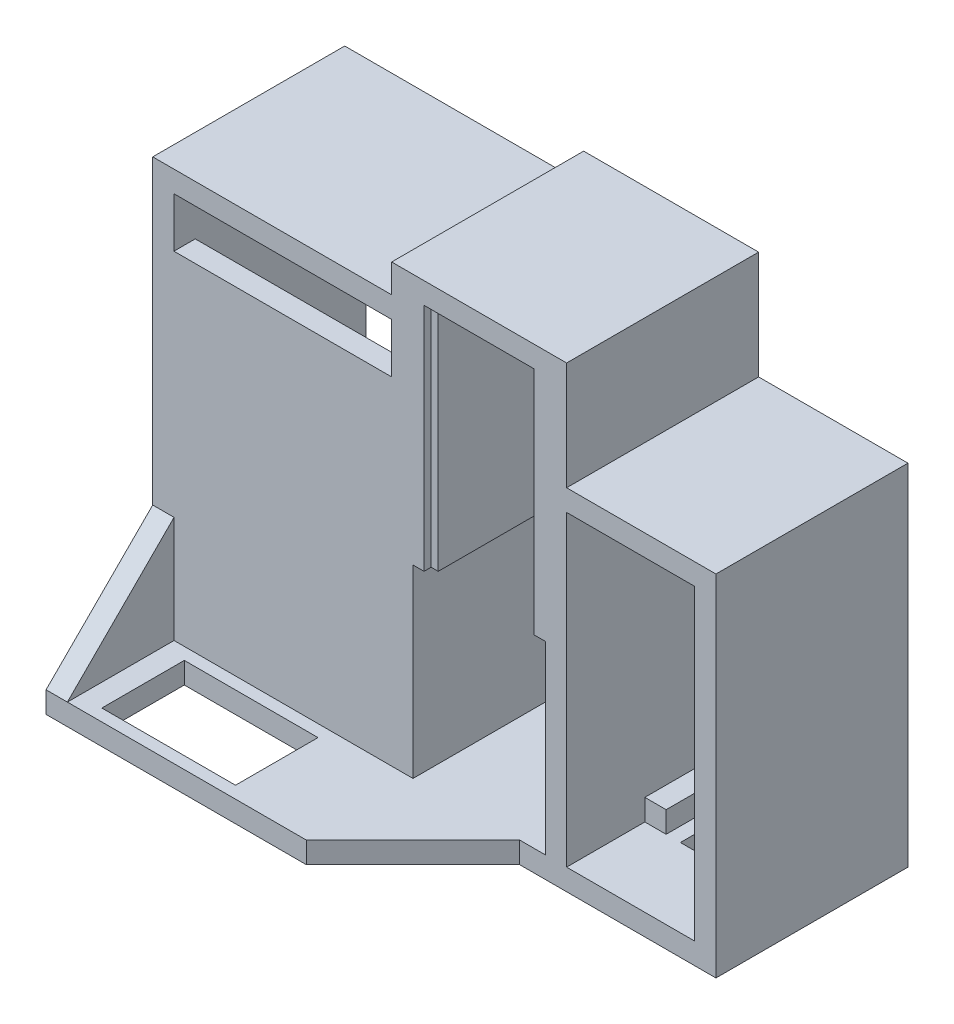
from build123d import *

# Parameters (mm, degrees)
SKETCH1_W            = 24.6
SKETCH1_H            = 64.4
BOSS_EXTRUDE1_DEPTH  = 3
SKETCH1_5_W          = 24.6
SKETCH1_5_H          = 64.4
BOSS_EXTRUDE2_DEPTH  = 26
BOSS_EXTRUDE4_DEPTH  = 35
SKETCH1_8_W          = 24.6
SKETCH1_8_H          = 64.4
BOSS_EXTRUDE5_DEPTH  = 27
BOSS_EXTRUDE6_DEPTH  = 3
BOSS_EXTRUDE7_DEPTH  = 2
SKETCH2_4_W          = 8
SKETCH2_4_H          = 3
BOSS_EXTRUDE8_DEPTH  = 11
SKETCH2_5_W          = 5
SKETCH2_5_H          = 3
BOSS_EXTRUDE9_DEPTH  = 27
SKETCH5_W            = 33.6
SKETCH5_H            = 60.4
BOSS_EXTRUDE11_DEPTH = 3
SKETCH5_5_W          = 30.618778274
SKETCH5_5_H          = 54.4
CUT_EXTRUDE3_DEPTH   = 3
BOSS_EXTRUDE12_DEPTH = 27
SKETCH6_W            = 30.618778274
SKETCH6_H            = 47.4
BOSS_EXTRUDE13_DEPTH = 3
SKETCH7_W            = 24.6
SKETCH7_H            = 8
CUT_EXTRUDE4_DEPTH   = 3
SKETCH8_W            = 11
SKETCH8_H            = 3
BOSS_EXTRUDE14_DEPTH = 8
SKETCH2_6_W          = 3
SKETCH2_6_H          = 3
SKETCH2_6_W_2        = 5
BOSS_EXTRUDE15_DEPTH = 16
SKETCH9_W            = 36.6
SKETCH9_H            = 3
BOSS_EXTRUDE16_DEPTH = 15
SKETCH10_W           = 18.8
SKETCH10_H           = 11.60179211
CUT_EXTRUDE5_DEPTH   = 15
BOSS_EXTRUDE17_DEPTH = 3
BOSS_EXTRUDE18_DEPTH = 3


with BuildPart() as part:
    # Sketch1 → Boss-Extrude1 (new body)
    with BuildSketch(Plane.XY):
        with Locations((-9.3, 29.2)):
            Rectangle(SKETCH1_W, SKETCH1_H)
    extrude(amount=BOSS_EXTRUDE1_DEPTH)

    # Sketch1_5 → Boss-Extrude2 (add)
    with BuildSketch(Plane.XY):
        with Locations((-9.3, 29.2)):
            Rectangle(SKETCH1_5_W, SKETCH1_5_H)
        Polygon((0, 0), (-18.6, 0), (-18.6, 26), (-16.05, 26), (-16.05, 58.4), (-2.55, 58.4), (-2.55, 26), (0, 26), align=None, mode=Mode.SUBTRACT)
    extrude(amount=BOSS_EXTRUDE2_DEPTH)

    # Sketch1_7 → Boss-Extrude4 (add)
    with BuildSketch(Plane.XY):
        Polygon((3, 0), (0, 0), (-18.6, 0), (-21.6, 0), (-21.6, -3), (3, -3), align=None)
    extrude(amount=BOSS_EXTRUDE4_DEPTH)

    # Sketch1_8 → Boss-Extrude5 (add)
    with BuildSketch(Plane.XY):
        with Locations((-9.3, 29.2)):
            Rectangle(SKETCH1_8_W, SKETCH1_8_H)
        Polygon((0, 0), (-18.6, 0), (-18.6, 26), (-17.05, 26), (-17.05, 58.4), (-1.55, 58.4), (-1.55, 26), (0, 26), align=None, mode=Mode.SUBTRACT)
    extrude(amount=BOSS_EXTRUDE5_DEPTH)

    # Sketch2 → Boss-Extrude6 (add)
    with BuildSketch(Plane(origin=(0, 0, 0), x_dir=(-1, 0, 0), z_dir=(0, 0, -1))):
        Polygon((-8, 0), (-6, 0), (-6, 3), (-3, 3), (-3, 40.2), (-8, 40.2), (-8, 43.2), (-16, 43.2), (-16, 40.2), (-21, 40.2), (-21, 3), (-18, 3), (-18, 0), (-16, 0), align=None)
    extrude(amount=-BOSS_EXTRUDE6_DEPTH)

    # Sketch2_3 → Boss-Extrude7 (add)
    with BuildSketch(Plane(origin=(0, 0, 0), x_dir=(-1, 0, 0), z_dir=(0, 0, -1))):
        Polygon((-3, -3), (-3, 3), (-6, 3), (-6, 0), (-8, 0), (-8, -3), align=None)
        Polygon((-8, 40.2), (-3, 40.2), (-3, 46.2), (-24, 46.2), (-24, -3), (-16, -3), (-16, 0), (-18, 0), (-18, 3), (-21, 3), (-21, 40.2), (-16, 40.2), (-16, 43.2), (-8, 43.2), align=None)
    extrude(amount=-BOSS_EXTRUDE7_DEPTH)

    # Sketch2_4 → Boss-Extrude8 (add)
    with BuildSketch(Plane(origin=(0, 0, 0), x_dir=(-1, 0, 0), z_dir=(0, 0, -1))):
        with Locations((-12, -1.5)):
            Rectangle(SKETCH2_4_W, SKETCH2_4_H)
    extrude(amount=-BOSS_EXTRUDE8_DEPTH)

    # Sketch2_5 → Boss-Extrude9 (add)
    with BuildSketch(Plane(origin=(0, 0, 0), x_dir=(-1, 0, 0), z_dir=(0, 0, -1))):
        with Locations((-5.5, -1.5)):
            Rectangle(SKETCH2_5_W, SKETCH2_5_H)
        Polygon((-16, -3), (-16, 0), (-21, 0), (-21, 43.2), (-3, 43.2), (-3, 46.2), (-24, 46.2), (-24, -3), align=None)
    extrude(amount=-BOSS_EXTRUDE9_DEPTH)

    # Sketch5 → Boss-Extrude11 (add)
    with BuildSketch(Plane(origin=(0, 0, 0), x_dir=(-1, 0, 0), z_dir=(0, 0, -1))):
        with Locations((38.4, 27.2)):
            Rectangle(SKETCH5_W, SKETCH5_H)
    extrude(amount=-BOSS_EXTRUDE11_DEPTH)

    # Sketch5_5 → Cut-Extrude3 (cut)
    with BuildSketch(Plane(origin=(0, 0, 0), x_dir=(-1, 0, 0), z_dir=(0, 0, -1))):
        with Locations((36.909389137, 27.2)):
            Rectangle(SKETCH5_5_W, SKETCH5_5_H)
    extrude(amount=-CUT_EXTRUDE3_DEPTH, mode=Mode.SUBTRACT)

    # Sketch5_6 → Boss-Extrude12 (add)
    with BuildSketch(Plane(origin=(0, 0, 0), x_dir=(-1, 0, 0), z_dir=(0, 0, -1))):
        Polygon((21.6, 0), (21.6, -3), (55.2, -3), (55.2, 57.4), (21.6, 57.4), (21.6, 54.4), (52.218778274, 54.4), (52.218778274, 0), align=None)
    extrude(amount=-BOSS_EXTRUDE12_DEPTH)

    # Sketch6 → Boss-Extrude13 (add)
    with BuildSketch(Plane.XY.offset(27)):
        with Locations((-36.909389137, 23.7)):
            Rectangle(SKETCH6_W, SKETCH6_H)
    extrude(amount=-BOSS_EXTRUDE13_DEPTH)

    # Sketch7 → Cut-Extrude4 (cut)
    with BuildSketch(Plane.XZ.offset(3)):
        with Locations((-9.3, 31)):
            Rectangle(SKETCH7_W, SKETCH7_H)
    extrude(amount=-CUT_EXTRUDE4_DEPTH, mode=Mode.SUBTRACT)

    # Sketch8 → Boss-Extrude14 (add)
    with BuildSketch(Plane(origin=(8, 0, 0), x_dir=(0, 0, -1), z_dir=(1, 0, 0))):
        with Locations((-21.5, -1.5)):
            Rectangle(SKETCH8_W, SKETCH8_H)
    extrude(amount=BOSS_EXTRUDE14_DEPTH)

    # Sketch2_6 → Boss-Extrude15 (add)
    with BuildSketch(Plane(origin=(0, 0, 0), x_dir=(-1, 0, 0), z_dir=(0, 0, -1))):
        with Locations((-4.5, 1.5)):
            Rectangle(SKETCH2_6_W, SKETCH2_6_H)
        with Locations((-5.5, 41.7)):
            Rectangle(SKETCH2_6_W_2, SKETCH2_6_H)
        with Locations((-19.5, 1.5)):
            Rectangle(SKETCH2_6_W, SKETCH2_6_H)
        with Locations((-18.5, 41.7)):
            Rectangle(SKETCH2_6_W_2, SKETCH2_6_H)
    extrude(amount=-BOSS_EXTRUDE15_DEPTH)

    # Sketch9 → Boss-Extrude16 (add)
    with BuildSketch(Plane.XY.offset(27)):
        with Locations((-36.9, -1.5)):
            Rectangle(SKETCH9_W, SKETCH9_H)
    extrude(amount=BOSS_EXTRUDE16_DEPTH)

    # Sketch10 → Cut-Extrude5 (cut)
    with BuildSketch(Plane(origin=(0, -3, 0), x_dir=(-1, 0, 0), z_dir=(0, -1, 0))):
        with Locations((39.656308117, -34.500896055)):
            Rectangle(SKETCH10_W, SKETCH10_H)
    extrude(amount=-CUT_EXTRUDE5_DEPTH, mode=Mode.SUBTRACT)

    # Sketch11 → Boss-Extrude17 (add)
    with BuildSketch(Plane(origin=(0, -3, 0), x_dir=(-1, 0, 0), z_dir=(0, -1, 0))):
        Polygon((18.6, -42), (18.6, -27), (3.6, -27), align=None)
    extrude(amount=-BOSS_EXTRUDE17_DEPTH)

    # Sketch12 → Boss-Extrude18 (add)
    with BuildSketch(Plane.ZY.offset(55.2)):
        Polygon((27, 0), (42, 0), (27, 15), align=None)
    extrude(amount=-BOSS_EXTRUDE18_DEPTH)


solid = part.part
